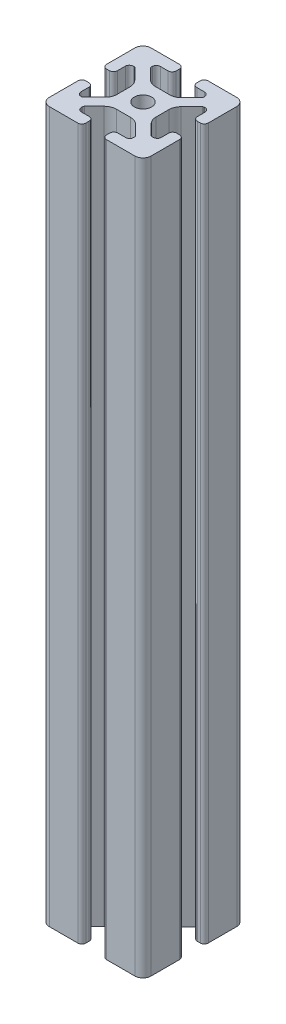
from build123d import *

# Parameters (mm, degrees)
SKETCH12_R               = 3.4
F_40_SERIES_4040_1_DEPTH = 279.4


with BuildPart() as part:
    # Sketch12 → 40 series 4040(1) (new body)
    with BuildSketch(Plane(origin=(0, 0, 0), x_dir=(-1, 0, 0), z_dir=(0, 1, 0))):
        with BuildLine():
            Line((-5.63, -15.524615034), (-8.715, -15.524615034))
            ThreePointArc((-8.715, -15.524615034), (-9.825157646, -15.06477268), (-10.285, -13.954615034))
            Line((-10.285, -13.954615034), (-10.285, -13.492503602))
            ThreePointArc((-10.285, -13.492503602), (-10.227148445, -13.201664194), (-10.062401154, -12.955102448))
            Line((-10.062401154, -12.955102448), (-6.217092793, -9.109794088))
            ThreePointArc((-6.217092793, -9.109794088), (-4.63891877, -8.055291919), (-2.777335583, -7.685))
            Line((-2.777335583, -7.685), (2.777335583, -7.685))
            ThreePointArc((2.777335583, -7.685), (4.63891877, -8.055291919), (6.217092793, -9.109794088))
            Line((6.217092793, -9.109794088), (10.062401154, -12.955102448))
            ThreePointArc((10.062401154, -12.955102448), (10.227148445, -13.201664194), (10.285, -13.492503602))
            Line((10.285, -13.492503602), (10.285, -13.954615034))
            ThreePointArc((10.285, -13.954615034), (9.825157646, -15.06477268), (8.715, -15.524615034))
            Line((8.715, -15.524615034), (5.63, -15.524615034))
            ThreePointArc((5.63, -15.524615034), (4.519842354, -15.984457388), (4.06, -17.094615034))
            Line((4.06, -17.094615034), (4.06, -18.43))
            ThreePointArc((4.06, -18.43), (4.519842354, -19.540157646), (5.63, -20))
            Line((5.63, -20), (16.83, -20))
            ThreePointArc((16.83, -20), (19.071528496, -19.071528496), (20, -16.83))
            Line((20, -16.83), (20, -5.63))
            ThreePointArc((20, -5.63), (19.540157461, -4.519842693), (18.43, -4.060000526))
            Line((18.43, -4.060000526), (17.24999625, -4.060000526))
            ThreePointArc((17.24999625, -4.060000526), (16.139838603, -4.519842879), (15.67999625, -5.630000526))
            Line((15.67999625, -5.630000526), (15.67999625, -8.715399492))
            ThreePointArc((15.67999625, -8.715399492), (15.220153896, -9.825557139), (14.10999625, -10.285399492))
            Line((14.10999625, -10.285399492), (13.6200547, -10.285399492))
            ThreePointArc((13.6200547, -10.285399492), (13.35903797, -10.160433474), (13.163657296, -9.946956002))
            Line((13.163657296, -9.946956002), (9.076242789, -5.859541495))
            ThreePointArc((9.076242789, -5.859541495), (8.046572221, -4.318530588), (7.685, -2.500784284))
            Line((7.685, -2.500784284), (7.685, 2.500784284))
            ThreePointArc((7.685, 2.500784284), (8.046572221, 4.318530588), (9.076242789, 5.859541495))
            Line((9.076242789, 5.859541495), (13.279501941, 10.062800646))
            ThreePointArc((13.279501941, 10.062800646), (13.526063686, 10.227547937), (13.816903094, 10.285399492))
            Line((13.816903094, 10.285399492), (14.10999625, 10.285399492))
            ThreePointArc((14.10999625, 10.285399492), (15.220153896, 9.825557139), (15.67999625, 8.715399492))
            Line((15.67999625, 8.715399492), (15.67999625, 5.630000526))
            ThreePointArc((15.67999625, 5.630000526), (16.139838603, 4.519842879), (17.24999625, 4.060000526))
            Line((17.24999625, 4.060000526), (18.43, 4.060000526))
            ThreePointArc((18.43, 4.060000526), (19.540157461, 4.519842693), (20, 5.63))
            Line((20, 5.63), (20, 16.83))
            ThreePointArc((20, 16.83), (19.071528496, 19.071528496), (16.83, 20))
            Line((16.83, 20), (5.63, 20))
            ThreePointArc((5.63, 20), (4.519842354, 19.540157646), (4.06, 18.43))
            Line((4.06, 18.43), (4.06, 17.094615034))
            ThreePointArc((4.06, 17.094615034), (4.519842354, 15.984457388), (5.63, 15.524615034))
            Line((5.63, 15.524615034), (8.715, 15.524615034))
            ThreePointArc((8.715, 15.524615034), (9.825157646, 15.06477268), (10.285, 13.954615034))
            Line((10.285, 13.954615034), (10.285, 13.492503602))
            ThreePointArc((10.285, 13.492503602), (10.227148445, 13.201664194), (10.062401154, 12.955102448))
            Line((10.062401154, 12.955102448), (6.217092793, 9.109794088))
            ThreePointArc((6.217092793, 9.109794088), (4.63891877, 8.055291919), (2.777335583, 7.685))
            Line((2.777335583, 7.685), (-2.777335583, 7.685))
            ThreePointArc((-2.777335583, 7.685), (-4.63891877, 8.055291919), (-6.217092793, 9.109794088))
            Line((-6.217092793, 9.109794088), (-10.062401154, 12.955102448))
            ThreePointArc((-10.062401154, 12.955102448), (-10.227148445, 13.201664194), (-10.285, 13.492503602))
            Line((-10.285, 13.492503602), (-10.285, 13.954615034))
            ThreePointArc((-10.285, 13.954615034), (-9.825157646, 15.06477268), (-8.715, 15.524615034))
            Line((-8.715, 15.524615034), (-5.63, 15.524615034))
            ThreePointArc((-5.63, 15.524615034), (-4.519842354, 15.984457388), (-4.06, 17.094615034))
            Line((-4.06, 17.094615034), (-4.06, 18.43))
            ThreePointArc((-4.06, 18.43), (-4.519842354, 19.540157646), (-5.63, 20))
            Line((-5.63, 20), (-16.83, 20))
            ThreePointArc((-16.83, 20), (-19.071528496, 19.071528496), (-20, 16.83))
            Line((-20, 16.83), (-20, 5.572979049))
            ThreePointArc((-20, 5.572979049), (-19.540157646, 4.462821403), (-18.43, 4.002979049))
            Line((-18.43, 4.002979049), (-17.25, 4.002979049))
            ThreePointArc((-17.25, 4.002979049), (-16.139842354, 4.462821403), (-15.68, 5.572979049))
            Line((-15.68, 5.572979049), (-15.68, 8.475666998))
            ThreePointArc((-15.68, 8.475666998), (-15.200613642, 9.605030484), (-14.05520779, 10.044710596))
            Line((-14.05520779, 10.044710596), (-13.71989919, 10.033001362))
            ThreePointArc((-13.71989919, 10.033001362), (-13.354224618, 10.012729352), (-13.040489136, 9.823787841))
            Line((-13.040489136, 9.823787841), (-9.076242789, 5.859541495))
            ThreePointArc((-9.076242789, 5.859541495), (-8.046572221, 4.318530588), (-7.685, 2.500784284))
            Line((-7.685, 2.500784284), (-7.685, -2.500784284))
            ThreePointArc((-7.685, -2.500784284), (-8.046572221, -4.318530588), (-9.076242789, -5.859541495))
            Line((-9.076242789, -5.859541495), (-13.279501941, -10.062800646))
            ThreePointArc((-13.279501941, -10.062800646), (-13.526061711, -10.227547119), (-13.816898819, -10.285399492))
            Line((-13.816898819, -10.285399492), (-14.10999625, -10.285399492))
            ThreePointArc((-14.10999625, -10.285399492), (-15.220153896, -9.825557139), (-15.67999625, -8.715399492))
            Line((-15.67999625, -8.715399492), (-15.67999625, -5.757919334))
            ThreePointArc((-15.67999625, -5.757919334), (-16.115287682, -4.60388249), (-17.25, -4.120449326))
            Line((-17.25, -4.120449326), (-18.43, -4.120449326))
            ThreePointArc((-18.43, -4.120449326), (-19.564709668, -4.603883664), (-20, -5.757918808))
            Line((-20, -5.757918808), (-20, -17.018368134))
            ThreePointArc((-20, -17.018368134), (-18.951578385, -19.194274381), (-16.674615034, -20))
            Line((-16.674615034, -20), (-5.63, -20))
            ThreePointArc((-5.63, -20), (-4.519842354, -19.540157646), (-4.06, -18.43))
            Line((-4.06, -18.43), (-4.06, -17.094615034))
            ThreePointArc((-4.06, -17.094615034), (-4.519842354, -15.984457388), (-5.63, -15.524615034))
        make_face()
        Circle(SKETCH12_R, mode=Mode.SUBTRACT)
    extrude(amount=F_40_SERIES_4040_1_DEPTH)


solid = part.part
